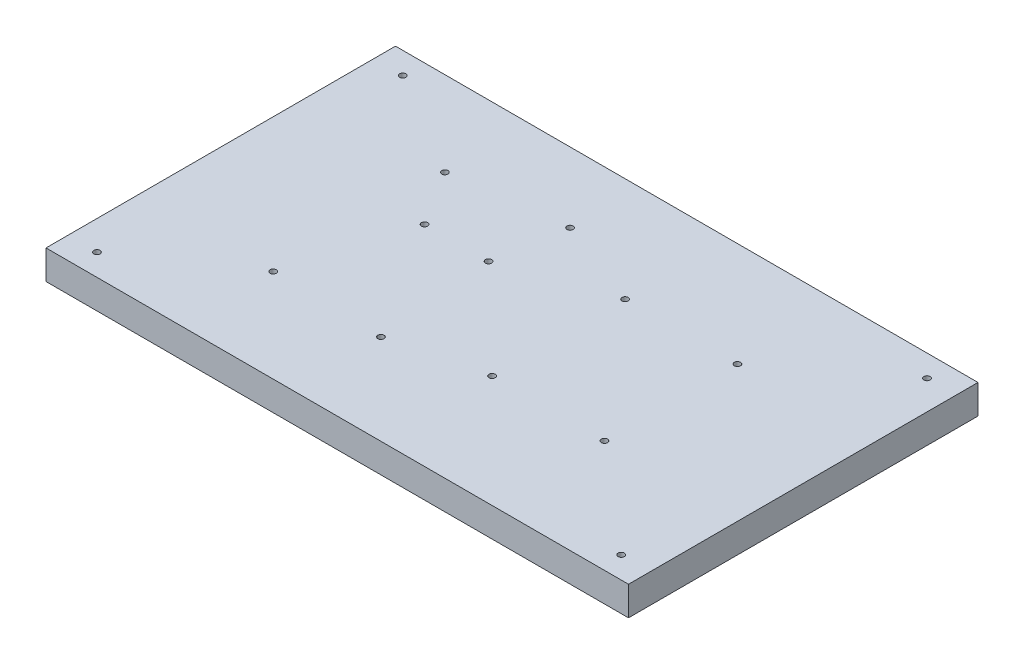
from build123d import *

# Parameters (mm, degrees)
ESQUISSE1_W            = 254
ESQUISSE1_H            = 152.4
BOSS_EXTRU_1_DEPTH     = 12.7
D_GAGEMENT_M2_51_D     = 2.7
D_GAGEMENT_M2_51_DEPTH = 8.89
D_GAGEMENT_M2_52_D     = 2.7
D_GAGEMENT_M2_52_DEPTH = 95.25


with BuildPart() as part:
    # Esquisse1 → Boss.-Extru.1 (new body)
    with BuildSketch(Plane(origin=(0, 0, 0), x_dir=(1, 0, 0), z_dir=(0, 1, 0))):
        with Locations((127, 76.2)):
            Rectangle(ESQUISSE1_W, ESQUISSE1_H)
    extrude(amount=BOSS_EXTRU_1_DEPTH)

    # Dégagement M2.51
    with Locations(Plane(origin=(0, 12.7, 0), x_dir=(1, 0, 0), z_dir=(0, 1, 0))):
        with Locations((194.619999888, 48.9), (194.619999888, 106.9), (145.619999888, 106.9), (145.619999888, 48.9), (106.64, 121.87), (58.42, 115.51), (101.56, 91.42), (73.65, 91.42), (58.42, 40.63), (106.64, 39.4)):
            Hole(D_GAGEMENT_M2_51_D / 2, depth=D_GAGEMENT_M2_51_DEPTH)

    # Dégagement M2.52
    with Locations(Plane(origin=(0, 12.7, 0), x_dir=(1, 0, 0), z_dir=(0, 1, 0))):
        with Locations((12.7, 9.525), (241.3, 9.525), (241.3, 142.875), (12.7, 142.875)):
            Hole(D_GAGEMENT_M2_52_D / 2, depth=D_GAGEMENT_M2_52_DEPTH)


solid = part.part
